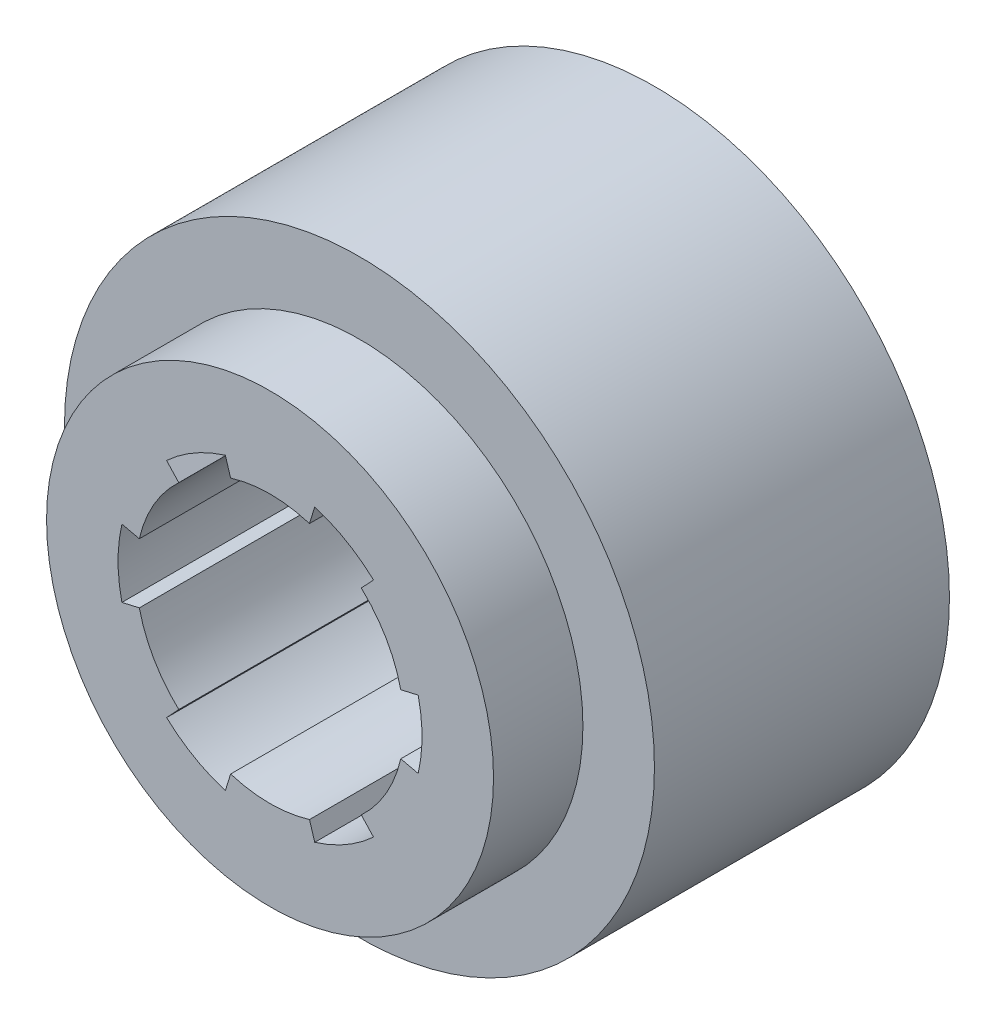
from build123d import *

# Parameters (mm, degrees)
IZIM1_R                     = 25
Y_KSEKLIK_EKSTR_ZYON1_DEPTH = 5
IZIM2_R                     = 33
Y_KSEKLIK_EKSTR_ZYON2_DEPTH = 33


with BuildPart() as part:
    # Çizim1 → Yükseklik-Ekstrüzyon1 (new body, symmetric)
    with BuildSketch(Plane.XY):
        Circle(IZIM1_R)
        with BuildLine():
            Line((-5, 16.248076809), (-4.411764706, 14.336538361))
            ThreePointArc((-4.411764706, 14.336538361), (0, 15), (4.411764706, 14.336538361))
            Line((4.411764706, 14.336538361), (5, 16.248076809))
            ThreePointArc((5, 16.248076809), (8.5, 14.722431864), (11.571247279, 12.454165424))
            Line((11.571247279, 12.454165424), (10.20992407, 10.988969491))
            ThreePointArc((10.20992407, 10.988969491), (12.990381057, 7.5), (14.621688776, 3.34756887))
            Line((14.621688776, 3.34756887), (16.571247279, 3.793911386))
            ThreePointArc((16.571247279, 3.793911386), (17, 0), (16.571247279, -3.793911386))
            Line((16.571247279, -3.793911386), (14.621688776, -3.34756887))
            ThreePointArc((14.621688776, -3.34756887), (12.990381057, -7.5), (10.20992407, -10.988969491))
            Line((10.20992407, -10.988969491), (11.571247279, -12.454165424))
            ThreePointArc((11.571247279, -12.454165424), (8.5, -14.722431864), (5, -16.248076809))
            Line((5, -16.248076809), (4.411764706, -14.336538361))
            ThreePointArc((4.411764706, -14.336538361), (0, -15), (-4.411764706, -14.336538361))
            Line((-4.411764706, -14.336538361), (-5, -16.248076809))
            ThreePointArc((-5, -16.248076809), (-8.5, -14.722431864), (-11.571247279, -12.454165424))
            Line((-11.571247279, -12.454165424), (-10.20992407, -10.988969491))
            ThreePointArc((-10.20992407, -10.988969491), (-12.990381057, -7.5), (-14.621688776, -3.34756887))
            Line((-14.621688776, -3.34756887), (-16.571247279, -3.793911386))
            ThreePointArc((-16.571247279, -3.793911386), (-17, 0), (-16.571247279, 3.793911386))
            Line((-16.571247279, 3.793911386), (-14.621688776, 3.34756887))
            ThreePointArc((-14.621688776, 3.34756887), (-12.990381057, 7.5), (-10.20992407, 10.988969491))
            Line((-10.20992407, 10.988969491), (-11.571247279, 12.454165424))
            ThreePointArc((-11.571247279, 12.454165424), (-8.5, 14.722431864), (-5, 16.248076809))
        make_face(mode=Mode.SUBTRACT)
    extrude(amount=Y_KSEKLIK_EKSTR_ZYON1_DEPTH, both=True)

    # Çizim2 → Yükseklik-Ekstrüzyon2 (add)
    with BuildSketch(Plane(origin=(0, 0, -5), x_dir=(-1, 0, 0), z_dir=(0, 0, -1))):
        Circle(IZIM2_R)
        with BuildLine():
            Line((-5, 16.248076809), (-4.411764706, 14.336538361))
            ThreePointArc((-4.411764706, 14.336538361), (0, 15), (4.411764706, 14.336538361))
            Line((4.411764706, 14.336538361), (5, 16.248076809))
            ThreePointArc((5, 16.248076809), (8.5, 14.722431864), (11.571247279, 12.454165424))
            Line((11.571247279, 12.454165424), (10.20992407, 10.988969491))
            ThreePointArc((10.20992407, 10.988969491), (12.990381057, 7.5), (14.621688776, 3.34756887))
            Line((14.621688776, 3.34756887), (16.571247279, 3.793911386))
            ThreePointArc((16.571247279, 3.793911386), (17, 0), (16.571247279, -3.793911386))
            Line((16.571247279, -3.793911386), (14.621688776, -3.34756887))
            ThreePointArc((14.621688776, -3.34756887), (12.990381057, -7.5), (10.20992407, -10.988969491))
            Line((10.20992407, -10.988969491), (11.571247279, -12.454165424))
            ThreePointArc((11.571247279, -12.454165424), (8.5, -14.722431864), (5, -16.248076809))
            Line((5, -16.248076809), (4.411764706, -14.336538361))
            ThreePointArc((4.411764706, -14.336538361), (0, -15), (-4.411764706, -14.336538361))
            Line((-4.411764706, -14.336538361), (-5, -16.248076809))
            ThreePointArc((-5, -16.248076809), (-8.5, -14.722431864), (-11.571247279, -12.454165424))
            Line((-11.571247279, -12.454165424), (-10.20992407, -10.988969491))
            ThreePointArc((-10.20992407, -10.988969491), (-12.990381057, -7.5), (-14.621688776, -3.34756887))
            Line((-14.621688776, -3.34756887), (-16.571247279, -3.793911386))
            ThreePointArc((-16.571247279, -3.793911386), (-17, 0), (-16.571247279, 3.793911386))
            Line((-16.571247279, 3.793911386), (-14.621688776, 3.34756887))
            ThreePointArc((-14.621688776, 3.34756887), (-12.990381057, 7.5), (-10.20992407, 10.988969491))
            Line((-10.20992407, 10.988969491), (-11.571247279, 12.454165424))
            ThreePointArc((-11.571247279, 12.454165424), (-8.5, 14.722431864), (-5, 16.248076809))
        make_face(mode=Mode.SUBTRACT)
    extrude(amount=Y_KSEKLIK_EKSTR_ZYON2_DEPTH)


solid = part.part
